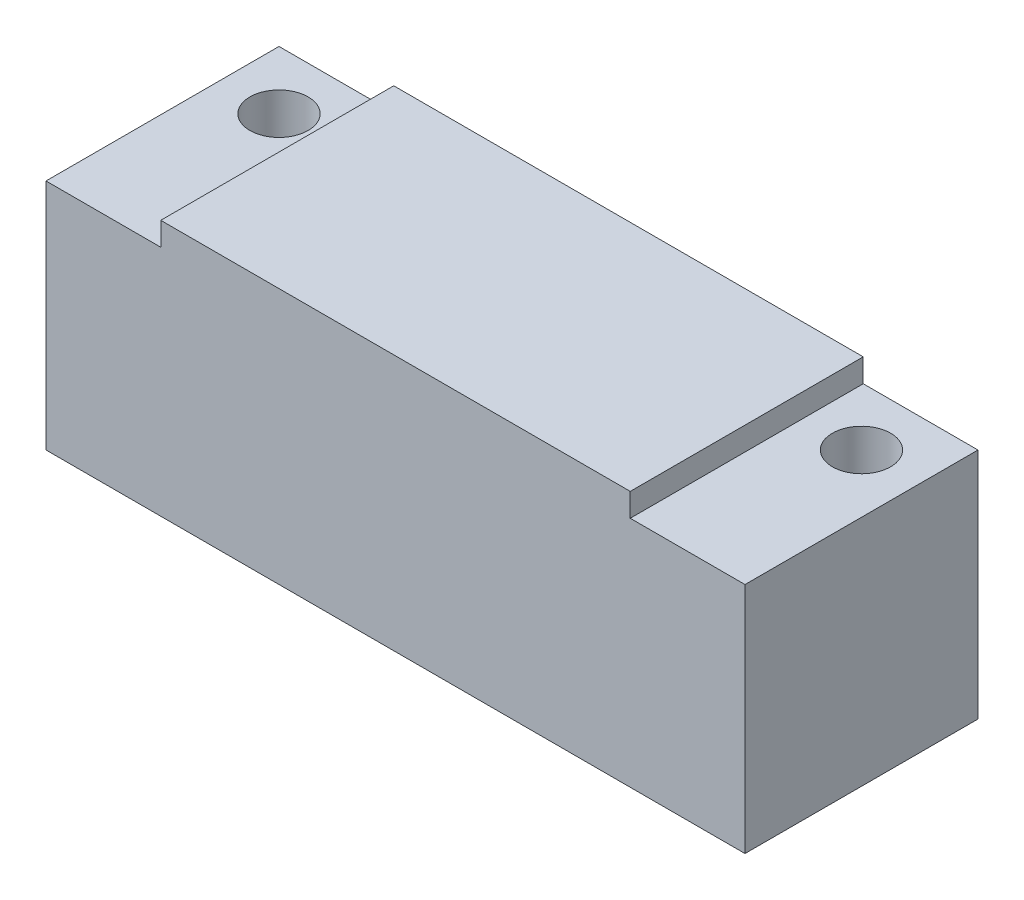
from build123d import *

# Parameters (mm, degrees)
BOSS_EXTRUDE1_DEPTH = 20
SKETCH2_R           = 2.5
CUT_EXTRUDE1_DEPTH  = 23


with BuildPart() as part:
    # Sketch1 → Boss-Extrude1 (new body)
    with BuildSketch(Plane.XY):
        Polygon((0, 0), (60, 0), (60, 20), (50.15, 20), (50.15, 22), (9.85, 22), (9.85, 20), (0, 20), align=None)
    extrude(amount=BOSS_EXTRUDE1_DEPTH)

    # Sketch2 → Cut-Extrude1 (cut, through all)
    with BuildSketch(Plane.XZ):
        with Locations((55, 5)):
            Circle(SKETCH2_R)
        with Locations((5, 5)):
            Circle(SKETCH2_R)
    extrude(amount=-CUT_EXTRUDE1_DEPTH, mode=Mode.SUBTRACT)


solid = part.part
